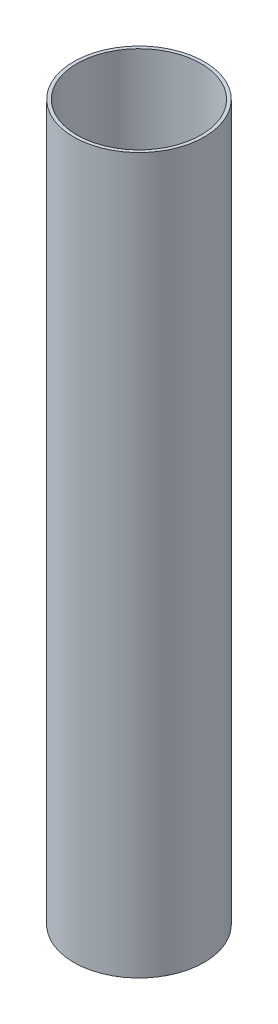
from build123d import *

# Parameters (mm, degrees)
SKETCH1_R           = 34.8996
SKETCH1_R_2         = 33.147
BOSS_EXTRUDE1_DEPTH = 382.1938


with BuildPart() as part:
    # Sketch1 → Boss-Extrude1 (new body)
    with BuildSketch(Plane(origin=(0, 0, 0), x_dir=(1, 0, 0), z_dir=(0, 1, 0))):
        Circle(SKETCH1_R)
        Circle(SKETCH1_R_2, mode=Mode.SUBTRACT)
    extrude(amount=BOSS_EXTRUDE1_DEPTH)


solid = part.part
